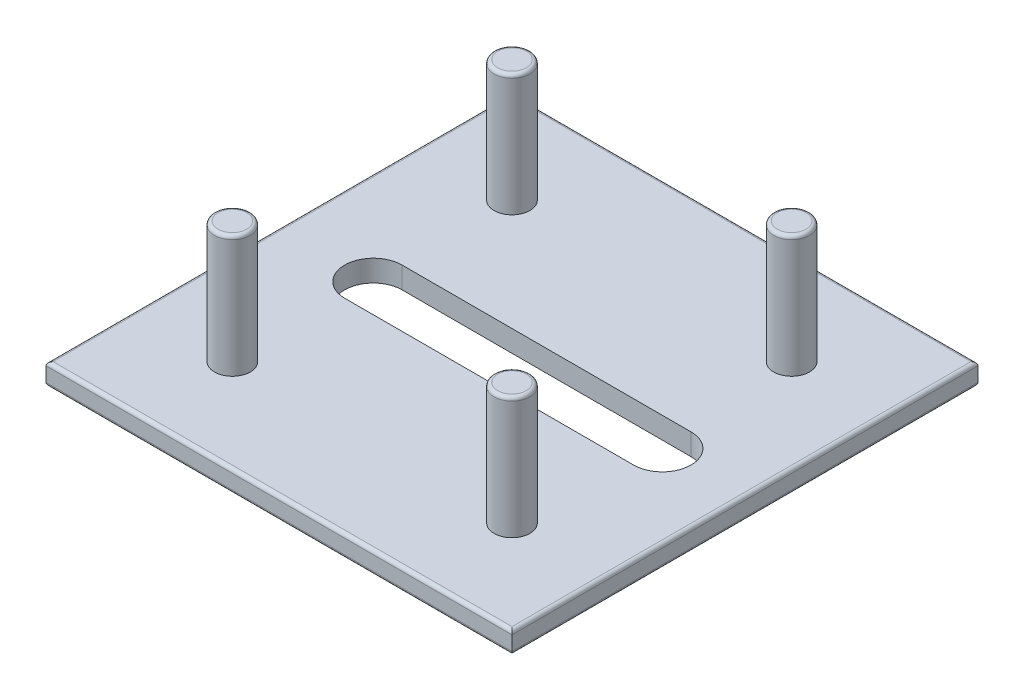
from build123d import *

# Parameters (mm, degrees)
SKETCH1_W           = 65
SKETCH1_H           = 65
BOSS_EXTRUDE1_DEPTH = 3
SKETCH2_R           = 2.5
BOSS_EXTRUDE2_DEPTH = 17
CUT_EXTRUDE1_DEPTH  = 21
FILLET1_R           = 0.5


with BuildPart() as part:
    # Sketch1 → Boss-Extrude1 (new body)
    with BuildSketch(Plane(origin=(0, 0, 0), x_dir=(1, 0, 0), z_dir=(0, 1, 0))):
        Rectangle(SKETCH1_W, SKETCH1_H)
    extrude(amount=BOSS_EXTRUDE1_DEPTH)

    # Sketch2 → Boss-Extrude2 (add)
    with BuildSketch(Plane(origin=(0, 3, 0), x_dir=(1, 0, 0), z_dir=(0, 1, 0))):
        with Locations((-19.5, 19.5)):
            Circle(SKETCH2_R)
        with Locations((19.5, 19.5)):
            Circle(SKETCH2_R)
        with Locations((-19.5, -19.5)):
            Circle(SKETCH2_R)
        with Locations((19.5, -19.5)):
            Circle(SKETCH2_R)
    extrude(amount=BOSS_EXTRUDE2_DEPTH)

    # Sketch3 → Cut-Extrude1 (cut, through all)
    with BuildSketch(Plane.XZ):
        with BuildLine():
            Line((-19.335806009, 4.005402362), (20.966240956, 4.005402362))
            ThreePointArc((20.966240956, 4.005402362), (24.971643318, 0), (20.966240956, -4.005402362))
            Line((20.966240956, -4.005402362), (-19.335806009, -4.005402362))
            ThreePointArc((-19.335806009, -4.005402362), (-23.34120837, 0), (-19.335806009, 4.005402362))
        make_face()
    extrude(amount=-CUT_EXTRUDE1_DEPTH, mode=Mode.SUBTRACT)

    # Fillet1
    fillet1_edges = [part.edges().sort_by_distance(p)[0] for p in [
        (-32.5, 3, 0),
        (-22, 20, -19.5),
        (0, 3, 32.5),
        (17, 20, -19.5),
        (-22, 20, 19.5),
        (17, 20, 19.5),
        (32.5, 3, 0),
        (0, 0, 32.5),
        (-32.5, 0, 0),
        (0, 0, -32.5),
        (32.5, 0, 0),
        (0, 3, -32.5),
    ]]
    fillet(fillet1_edges, radius=FILLET1_R)


solid = part.part
